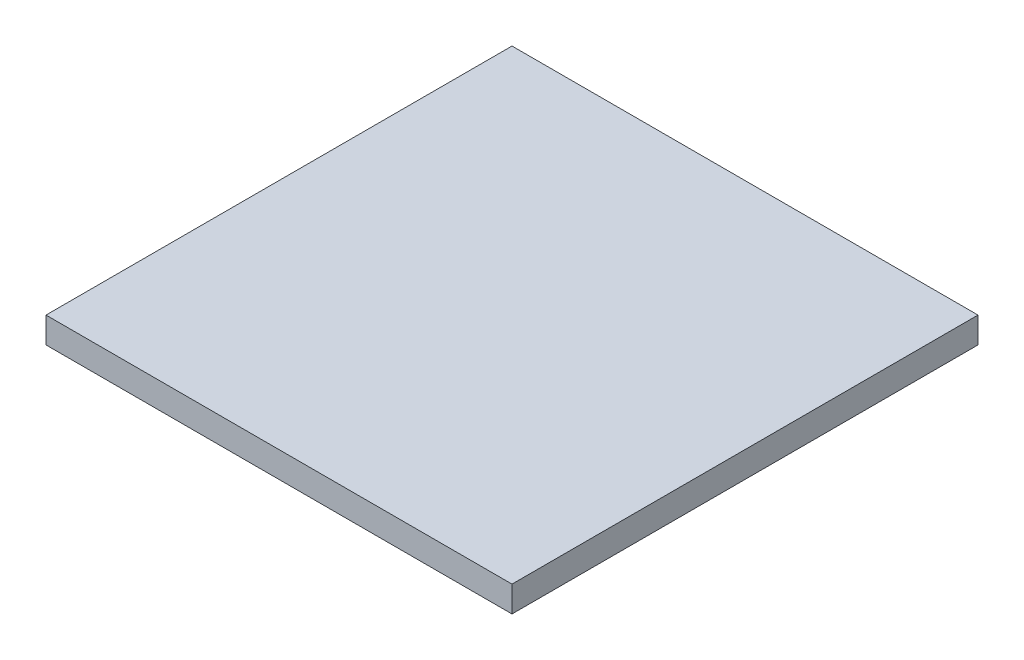
from build123d import *

# Parameters (mm, degrees)
SKIZZE1_W                       = 6.3
SKIZZE1_H                       = 6.3
AUFSATZ_LINEAR_AUSTRAGEN1_DEPTH = 0.35


with BuildPart() as part:
    # Skizze1 → Aufsatz-Linear austragen1 (new body)
    with BuildSketch(Plane(origin=(0, 0, 0), x_dir=(1, 0, 0), z_dir=(0, 1, 0))):
        Rectangle(SKIZZE1_W, SKIZZE1_H)
    extrude(amount=AUFSATZ_LINEAR_AUSTRAGEN1_DEPTH)


solid = part.part
